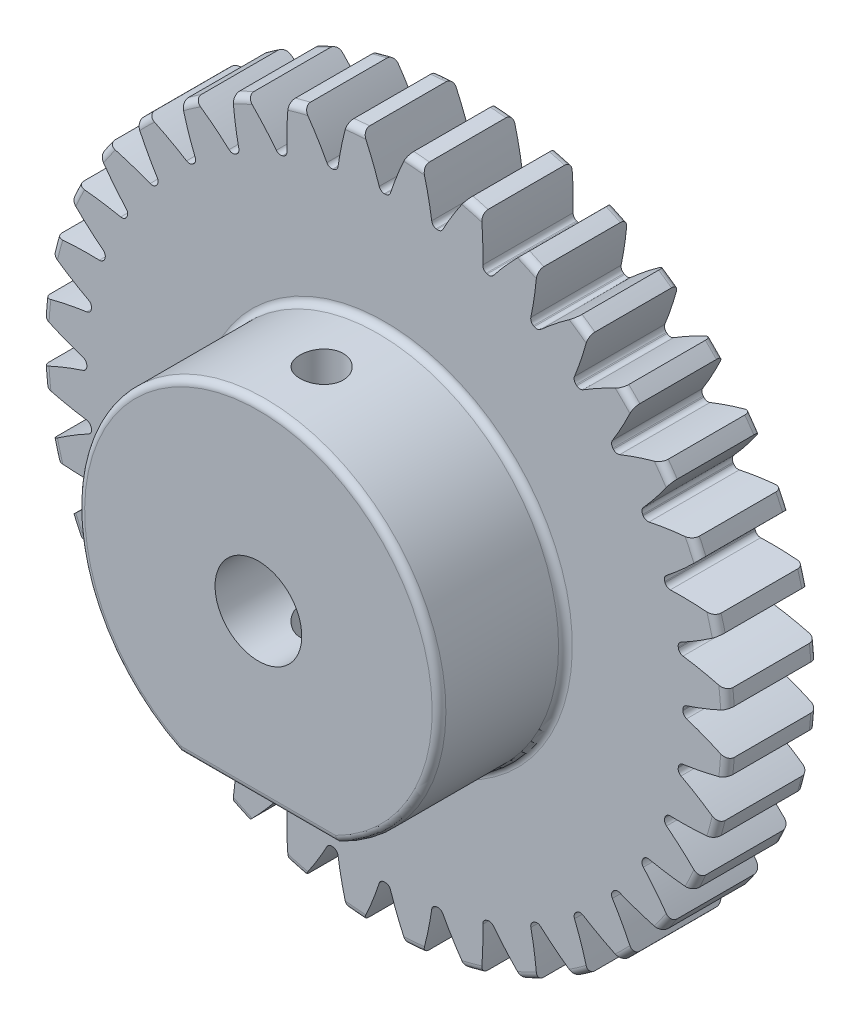
from build123d import *

# Parameters (mm, degrees)
FILLET2_R                   = 0.4826
CUT_EXTRUDE2_DEPTH          = 7.35
CIRPATTERN1_COUNT           = 36
CUT_EXTRUDE3_DEPTH          = 8.89
FILLET4_R                   = 0.4826
TAP_DRILL_FOR_4_HELICOIL1_D = 3.048


with BuildPart() as part:
    # Sketch4 → Revolve1 (revolve)
    with BuildSketch(Plane(origin=(0, 0, 0), x_dir=(0, 0, -1), z_dir=(1, 0, 0))):
        Polygon((-15.24, 3.048), (-15.24, 12.7), (-6.35, 12.7), (-6.35, 24.13), (0, 24.13), (0, 3.048), align=None)
    revolve(axis=Axis((0, 0, 6.35), (0, 0, 1)))

    # Fillet2
    fillet2_edges = [part.edges().sort_by_distance(p)[0] for p in [
        (0, -24.13, 0),
        (0, -24.13, 6.35),
    ]]
    fillet(fillet2_edges, radius=FILLET2_R)

    # Sketch7 → Cut-Extrude2 (cut, through all)
    with BuildSketch(Plane.XY.offset(6.35)):
        with BuildLine():
            ThreePointArc((-0.033786015, 20.954972763), (0, 20.955), (0.033786015, 20.954972763))
            ThreePointArc((0.033786015, 20.954972763), (0.257667087, 21.027237796), (0.396436516, 21.217206256))
            ThreePointArc((0.396436516, 21.217206256), (0.927466401, 22.668107551), (1.555288717, 24.079825103))
            ThreePointArc((1.555288717, 24.079825103), (0, 24.13), (-1.555288717, 24.079825103))
            ThreePointArc((-1.555288717, 24.079825103), (-0.927466401, 22.668107551), (-0.396436516, 21.217206256))
            ThreePointArc((-0.396436516, 21.217206256), (-0.257667087, 21.027237796), (-0.033786015, 20.954972763))
        make_face()
    cut_extrude2 = extrude(amount=-CUT_EXTRUDE2_DEPTH, mode=Mode.SUBTRACT)

    # CirPattern1: Cut-Extrude2 ×36 about axis
    cirpattern1_axis = Axis((0, 0, 0), (0, 0, 1))
    for i in range(1, CIRPATTERN1_COUNT):
        add(cut_extrude2.rotate(cirpattern1_axis, i * 360 / CIRPATTERN1_COUNT), mode=Mode.SUBTRACT)

    # Sketch8 → Cut-Extrude3 (cut)
    with BuildSketch(Plane.XY.offset(15.24)):
        with BuildLine():
            Line((5.535801658, -11.43), (-5.535801658, -11.43))
            ThreePointArc((-5.535801658, -11.43), (0, -12.7), (5.535801658, -11.43))
        make_face()
    extrude(amount=-CUT_EXTRUDE3_DEPTH, mode=Mode.SUBTRACT)

    # Fillet4
    fillet4_edges = [part.edges().sort_by_distance(p)[0] for p in [
        (0, 12.7, 6.35),
        (0, 12.7, 15.24),
        (0, -11.43, 15.24),
        (0, -11.43, 6.35),
    ]]
    fillet(fillet4_edges, radius=FILLET4_R)

    # Tap Drill for #4 Helicoil1 (through all)
    with Locations(Plane(origin=(0, -11.43, 0), x_dir=(-1, 0, 0), z_dir=(0, -1, 0))):
        with Locations((0, -10.795)):
            Hole(TAP_DRILL_FOR_4_HELICOIL1_D / 2)


solid = part.part
